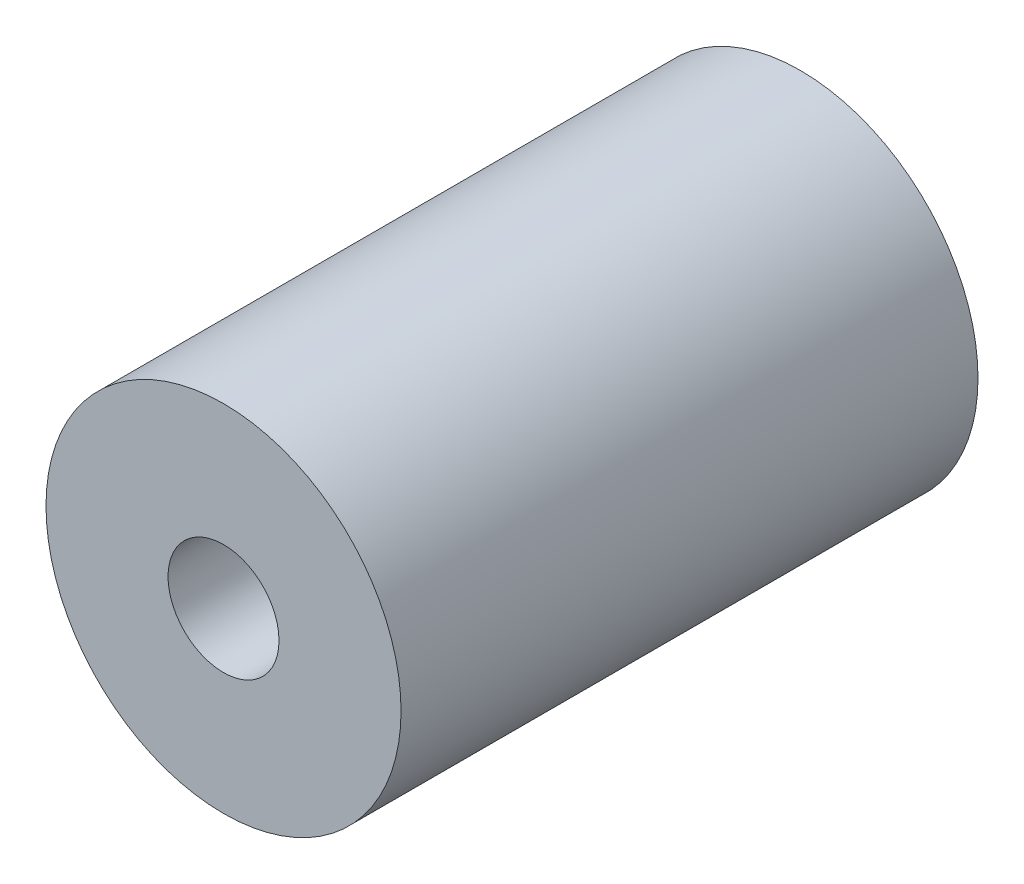
from build123d import *

# Parameters (mm, degrees)
SKETCH1_R           = 8
SKETCH1_R_2         = 2.5
BOSS_EXTRUDE1_DEPTH = 26
SKETCH2_R           = 3.5
CUT_EXTRUDE1_DEPTH  = 10


with BuildPart() as part:
    # Sketch1 → Boss-Extrude1 (new body)
    with BuildSketch(Plane.XY):
        Circle(SKETCH1_R)
        Circle(SKETCH1_R_2, mode=Mode.SUBTRACT)
    extrude(amount=BOSS_EXTRUDE1_DEPTH)

    # Sketch2 → Cut-Extrude1 (cut)
    with BuildSketch(Plane.XY.offset(18)):
        Circle(SKETCH2_R)
    extrude(amount=-CUT_EXTRUDE1_DEPTH, mode=Mode.SUBTRACT)


solid = part.part
